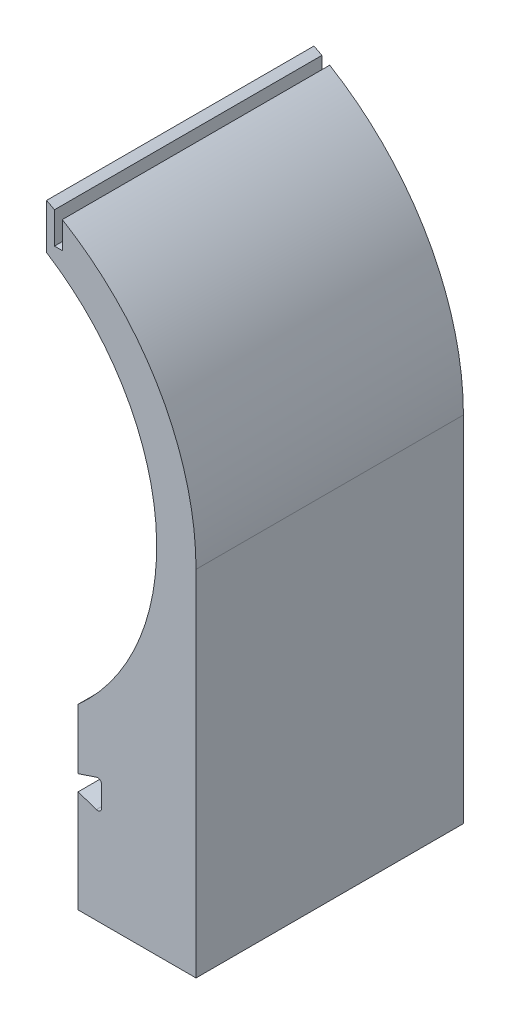
from build123d import *

# Parameters (mm, degrees)
INNER_RING_RIGHT_SIDE_DEPTH = 170


with BuildPart() as part:
    # Sketch2 → Inner Ring - Right Side (new body)
    with BuildSketch(Plane.XY):
        with BuildLine():
            Line((100, -111.803398875), (100, -150))
            Line((100, -150), (111.709430585, -146.096856472))
            ThreePointArc((111.709430585, -146.096856472), (113.961775712, -146.440459254), (115, -148.468564717))
            Line((115, -148.468564717), (115, -161.531435283))
            ThreePointArc((115, -161.531435283), (113.961775712, -163.559540746), (111.709430585, -163.903143528))
            Line((111.709430585, -163.903143528), (100, -160))
            Line((100, -160), (100, -225))
            Line((100, -225), (175, -225))
            Line((175, -225), (175, 0))
            ThreePointArc((175, 0), (152.274423328, 86.240941553), (90, 150.083310198))
            Line((90, 150.083310198), (90, 132.970585408))
            Line((90, 132.970585408), (85, 132.970585408))
            Line((85, 132.970585408), (85, 152.970585408))
            ThreePointArc((85, 152.970585408), (82.510826874, 154.327455265), (80, 155.643824163))
            Line((80, 155.643824163), (80, 126.885775404))
            ThreePointArc((80, 126.885775404), (149.476186998, 12.524756303), (100, -111.803398875))
        make_face()
    extrude(amount=INNER_RING_RIGHT_SIDE_DEPTH)


solid = part.part
